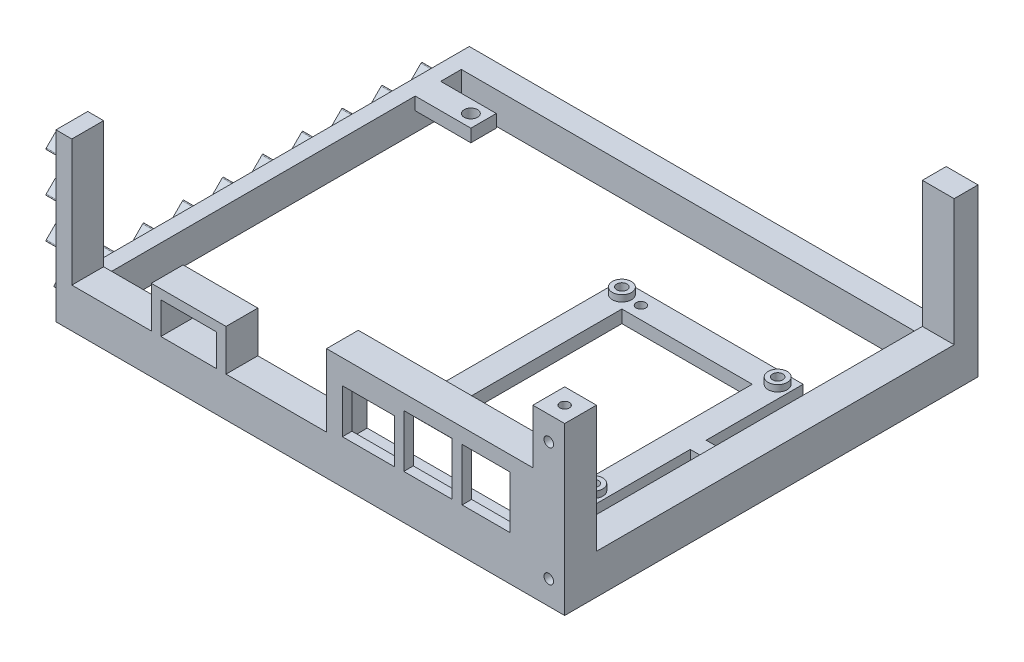
from build123d import *

# Parameters (mm, degrees)
SKETCH1_W           = 160
SKETCH1_H           = 130
BOSS_EXTRUDE1_DEPTH = 10
BOSS_EXTRUDE2_DEPTH = 42.3
CUT_EXTRUDE3_DEPTH  = 5.25
SKETCH9_R           = 2.1
CUT_EXTRUDE4_DEPTH  = 116.06211366
SKETCH11_W          = 112.5
SKETCH11_H          = 39.8
CUT_EXTRUDE5_DEPTH  = 172.640001165
SKETCH14_R          = 1.5
SKETCH14_W          = 41
SKETCH14_H          = 50
SKETCH14_R_2        = 1.625
BOSS_EXTRUDE7_DEPTH = 10
SKETCH14_3_R        = 3
SKETCH14_3_R_2      = 1.625
BOSS_EXTRUDE8_DEPTH = 12
SKETCH15_R          = 1.5
CUT_EXTRUDE7_DEPTH  = 4
CUT_EXTRUDE8_START  = -4
SKETCH16_R          = 1.5
CUT_EXTRUDE8_DEPTH  = 4
SKETCH17_W          = 17.5
SKETCH17_H          = 8
CUT_EXTRUDE9_DEPTH  = 6
SKETCH18_W          = 62.5
SKETCH18_H          = 80.5
CUT_EXTRUDE10_DEPTH = 6
SKETCH19_R          = 1.5
CUT_EXTRUDE11_DEPTH = 4
SKETCH21_W          = 16.4
SKETCH21_H          = 13.9
SKETCH21_W_2        = 15.2
SKETCH21_H_2        = 16.58376534
SKETCH21_W_3        = 15
SKETCH21_H_3        = 16.5018301
SKETCH21_W_4        = 17.5
SKETCH21_H_4        = 10
CUT_EXTRUDE14_DEPTH = 10
SKETCH22_W          = 57
SKETCH22_H          = 22.25
CUT_EXTRUDE16_DEPTH = 7
BOSS_EXTRUDE9_DEPTH = 5


with BuildPart() as part:
    # Sketch1 → Boss-Extrude1 (new body)
    with BuildSketch(Plane(origin=(0, 0, 0), x_dir=(1, 0, 0), z_dir=(0, 1, 0))):
        with Locations((5, 0)):
            Rectangle(SKETCH1_W, SKETCH1_H)
    extrude(amount=BOSS_EXTRUDE1_DEPTH)

    # Sketch3 → Boss-Extrude2 (add)
    with BuildSketch(Plane(origin=(0, 10, 0), x_dir=(1, 0, 0), z_dir=(0, 1, 0))):
        Polygon((75, 65), (75, -55), (-75, -55), (-75, -65), (85, -65), (85, 65), align=None)
    extrude(amount=BOSS_EXTRUDE2_DEPTH)

    # Sketch8 → Cut-Extrude3 (cut)
    with BuildSketch(Plane(origin=(0, 0, -65), x_dir=(-1, 0, 0), z_dir=(0, 0, -1))):
        Polygon((-83.425, 31.15), (-80, 34.575), (-76.575, 31.15), (-80, 27.725), align=None)
        Polygon((-80, 40.225), (-83.425, 43.65), (-80, 47.075), (-76.575, 43.65), align=None)
        Polygon((-80, 15.225), (-83.425, 18.65), (-80, 22.075), (-76.575, 18.65), align=None)
        Polygon((0, 8.425), (-3.425, 5), (0, 1.575), (3.425, 5), align=None)
        Polygon((15.925, 5), (12.5, 8.425), (9.075, 5), (12.5, 1.575), align=None)
        Polygon((28.425, 5), (25, 8.425), (21.575, 5), (25, 1.575), align=None)
        Polygon((40.925, 5), (37.5, 8.425), (34.075, 5), (37.5, 1.575), align=None)
        Polygon((53.425, 5), (50, 8.425), (46.575, 5), (50, 1.575), align=None)
        Polygon((65.925, 5), (62.5, 8.425), (59.075, 5), (62.5, 1.575), align=None)
        Polygon((-9.075, 5), (-12.5, 8.425), (-15.925, 5), (-12.5, 1.575), align=None)
        Polygon((-21.575, 5), (-25, 8.425), (-28.425, 5), (-25, 1.575), align=None)
        Polygon((-34.075, 5), (-37.5, 8.425), (-40.925, 5), (-37.5, 1.575), align=None)
        Polygon((-46.575, 5), (-50, 8.425), (-53.425, 5), (-50, 1.575), align=None)
        Polygon((-59.075, 5), (-62.5, 8.425), (-65.925, 5), (-62.5, 1.575), align=None)
        Polygon((-71.575, 5), (-75, 8.425), (-78.425, 5), (-75, 1.575), align=None)
    extrude(amount=-CUT_EXTRUDE3_DEPTH, mode=Mode.SUBTRACT)

    # Sketch9 → Cut-Extrude4 (cut, through all)
    with BuildSketch(Plane(origin=(0, 10, 0), x_dir=(1, 0, 0), z_dir=(0, 1, 0))):
        with Locations((-56.5, 47)):
            Circle(SKETCH9_R)
        Polygon((-70, -55), (75, -55), (75, 57.5), (-70, 57.5), (-70, 51), (-52.5, 51), (-52.5, 43), (-70, 43), align=None)
    extrude(amount=-CUT_EXTRUDE4_DEPTH, mode=Mode.SUBTRACT)

    # Sketch11 → Cut-Extrude5 (cut, through all)
    with BuildSketch(Plane.ZY.offset(-75)):
        with Locations((-1.25, 32.4)):
            Rectangle(SKETCH11_W, SKETCH11_H)
    extrude(amount=-CUT_EXTRUDE5_DEPTH, mode=Mode.SUBTRACT)

    # Sketch14 → Boss-Extrude7 (add)
    with BuildSketch(Plane(origin=(0, 0, 0), x_dir=(1, 0, 0), z_dir=(0, 1, 0))):
        Polygon((69.5, -40.5), (69.5, -9.999989951), (75, -9.999989951), (75.01417657, -5.000010049), (69.5, -5.000010049), (69.5, 25.5), (12.5, 25.5), (12.5, -40.5), align=None)
        with Locations((59.5, -36.5)):
            Circle(SKETCH14_R, mode=Mode.SUBTRACT)
        with Locations((41, -7.5)):
            Rectangle(SKETCH14_W, SKETCH14_H, mode=Mode.SUBTRACT)
        with Locations((22.5, 21.5)):
            Circle(SKETCH14_R, mode=Mode.SUBTRACT)
        with Locations((16.5, -36.5)):
            Circle(SKETCH14_R_2, mode=Mode.SUBTRACT)
        with Locations((65.5, -36.5)):
            Circle(SKETCH14_R_2, mode=Mode.SUBTRACT)
        with Locations((16.5, 21.5)):
            Circle(SKETCH14_R_2, mode=Mode.SUBTRACT)
        with Locations((65.5, 21.5)):
            Circle(SKETCH14_R_2, mode=Mode.SUBTRACT)
    extrude(amount=BOSS_EXTRUDE7_DEPTH)

    # Sketch14_3 → Boss-Extrude8 (add)
    # profile 1 of 4: a face of its own
    with BuildSketch(Plane(origin=(0, 0, 0), x_dir=(1, 0, 0), z_dir=(0, 1, 0))):
        with Locations((16.5, -36.5)):
            Circle(SKETCH14_3_R)
        with Locations((16.5, -36.5)):
            Circle(SKETCH14_3_R_2, mode=Mode.SUBTRACT)
    # profile 2 of 4: a face of its own
    with BuildSketch(Plane(origin=(0, 0, 0), x_dir=(1, 0, 0), z_dir=(0, 1, 0))):
        with Locations((65.5, -36.5)):
            Circle(SKETCH14_3_R)
        with Locations((65.5, -36.5)):
            Circle(SKETCH14_3_R_2, mode=Mode.SUBTRACT)
    # profile 3 of 4: a face of its own
    with BuildSketch(Plane(origin=(0, 0, 0), x_dir=(1, 0, 0), z_dir=(0, 1, 0))):
        with Locations((16.5, 21.5)):
            Circle(SKETCH14_3_R)
        with Locations((16.5, 21.5)):
            Circle(SKETCH14_3_R_2, mode=Mode.SUBTRACT)
    # profile 4 of 4: a face of its own
    with BuildSketch(Plane(origin=(0, 0, 0), x_dir=(1, 0, 0), z_dir=(0, 1, 0))):
        with Locations((65.5, 21.5)):
            Circle(SKETCH14_3_R)
        with Locations((65.5, 21.5)):
            Circle(SKETCH14_3_R_2, mode=Mode.SUBTRACT)
    extrude(amount=BOSS_EXTRUDE8_DEPTH)

    # Sketch15 → Cut-Extrude7 (cut)
    with BuildSketch(Plane(origin=(0, 52.3, 0), x_dir=(1, 0, 0), z_dir=(0, 1, 0))):
        with Locations((80, -60)):
            Circle(SKETCH15_R)
    extrude(amount=-CUT_EXTRUDE7_DEPTH, mode=Mode.SUBTRACT)

    # Sketch16 → Cut-Extrude8 (cut)
    with BuildSketch(Plane.XZ.offset(CUT_EXTRUDE8_START)):
        with Locations((80, 60)):
            Circle(SKETCH16_R)
    extrude(amount=CUT_EXTRUDE8_DEPTH, mode=Mode.SUBTRACT)

    # Sketch17 → Cut-Extrude9 (cut)
    with BuildSketch(Plane.XZ):
        with Locations((-61.25, -47)):
            Rectangle(SKETCH17_W, SKETCH17_H)
    extrude(amount=-CUT_EXTRUDE9_DEPTH, mode=Mode.SUBTRACT)

    # Sketch18 → Cut-Extrude10 (cut)
    with BuildSketch(Plane.XZ):
        with Locations((43.75, 14.75)):
            Rectangle(SKETCH18_W, SKETCH18_H)
    extrude(amount=-CUT_EXTRUDE10_DEPTH, mode=Mode.SUBTRACT)

    # Sketch19 → Cut-Extrude11 (cut)
    with BuildSketch(Plane.XY.offset(65)):
        with Locations((80, 7.5)):
            Circle(SKETCH19_R)
        with Locations((80, 44.8)):
            Circle(SKETCH19_R)
    extrude(amount=-CUT_EXTRUDE11_DEPTH, mode=Mode.SUBTRACT)

    # Sketch21 → Cut-Extrude14 (cut)
    with BuildSketch(Plane.XY.offset(65)):
        Polygon((-70, 52.3), (-70, 12.5), (-45, 12.5), (-45, 25.5), (-21.5, 25.5), (-21.5, 12.5), (10.1, 12.5), (10.1, 35.25), (75, 35.25), (75, 52.3), align=None)
        with Locations((23.3, 20.7)):
            Rectangle(SKETCH21_W, SKETCH21_H)
        with Locations((42, 22.25)):
            Rectangle(SKETCH21_W_2, SKETCH21_H_2)
        with Locations((60.25, 22.25)):
            Rectangle(SKETCH21_W_3, SKETCH21_H_3)
        with Locations((-33.25, 17.5)):
            Rectangle(SKETCH21_W_4, SKETCH21_H_4)
    extrude(amount=-CUT_EXTRUDE14_DEPTH, mode=Mode.SUBTRACT)

    # Sketch22 → Cut-Extrude16 (cut)
    with BuildSketch(Plane(origin=(0, 0, 55), x_dir=(-1, 0, 0), z_dir=(0, 0, -1))):
        with Locations((-41.4, 21.125)):
            Rectangle(SKETCH22_W, SKETCH22_H)
    extrude(amount=-CUT_EXTRUDE16_DEPTH, mode=Mode.SUBTRACT)

    # Sketch10 → Boss-Extrude9 (add)
    with BuildSketch(Plane.ZY.offset(75)):
        with BuildLine():
            Line((10.537867966, 5.212132034), (7.712132034, 8.037867966))
            ThreePointArc((7.712132034, 8.037867966), (7.5, 8.125735931), (7.287867966, 8.037867966))
            Line((7.287867966, 8.037867966), (4.462132034, 5.212132034))
            ThreePointArc((4.462132034, 5.212132034), (4.374264069, 5), (4.462132034, 4.787867966))
            Line((4.462132034, 4.787867966), (7.287867966, 1.962132034))
            ThreePointArc((7.287867966, 1.962132034), (7.5, 1.874264069), (7.712132034, 1.962132034))
            Line((7.712132034, 1.962132034), (10.537867966, 4.787867966))
            ThreePointArc((10.537867966, 4.787867966), (10.625735931, 5), (10.537867966, 5.212132034))
        make_face()
        with BuildLine():
            Line((56.962132034, 31.362132034), (59.787867966, 34.187867966))
            ThreePointArc((59.787867966, 34.187867966), (60, 34.275735931), (60.212132034, 34.187867966))
            Line((60.212132034, 34.187867966), (63.037867966, 31.362132034))
            ThreePointArc((63.037867966, 31.362132034), (63.125735931, 31.15), (63.037867966, 30.937867966))
            Line((63.037867966, 30.937867966), (60.212132034, 28.112132034))
            ThreePointArc((60.212132034, 28.112132034), (60, 28.024264069), (59.787867966, 28.112132034))
            Line((59.787867966, 28.112132034), (56.962132034, 30.937867966))
            ThreePointArc((56.962132034, 30.937867966), (56.874264069, 31.15), (56.962132034, 31.362132034))
        make_face()
        with BuildLine():
            Line((-5.212132034, 8.037867966), (-8.037867966, 5.212132034))
            ThreePointArc((-8.037867966, 5.212132034), (-8.125735931, 5), (-8.037867966, 4.787867966))
            Line((-8.037867966, 4.787867966), (-5.212132034, 1.962132034))
            ThreePointArc((-5.212132034, 1.962132034), (-5, 1.874264069), (-4.787867966, 1.962132034))
            Line((-4.787867966, 1.962132034), (-1.962132034, 4.787867966))
            ThreePointArc((-1.962132034, 4.787867966), (-1.874264069, 5), (-1.962132034, 5.212132034))
            Line((-1.962132034, 5.212132034), (-4.787867966, 8.037867966))
            ThreePointArc((-4.787867966, 8.037867966), (-5, 8.125735931), (-5.212132034, 8.037867966))
        make_face()
        with BuildLine():
            Line((59.787867966, 40.612132034), (56.962132034, 43.437867966))
            ThreePointArc((56.962132034, 43.437867966), (56.874264069, 43.65), (56.962132034, 43.862132034))
            Line((56.962132034, 43.862132034), (59.787867966, 46.687867966))
            ThreePointArc((59.787867966, 46.687867966), (60, 46.775735931), (60.212132034, 46.687867966))
            Line((60.212132034, 46.687867966), (63.037867966, 43.862132034))
            ThreePointArc((63.037867966, 43.862132034), (63.125735931, 43.65), (63.037867966, 43.437867966))
            Line((63.037867966, 43.437867966), (60.212132034, 40.612132034))
            ThreePointArc((60.212132034, 40.612132034), (60, 40.524264069), (59.787867966, 40.612132034))
        make_face()
        with BuildLine():
            Line((59.787867966, 15.612132034), (56.962132034, 18.437867966))
            ThreePointArc((56.962132034, 18.437867966), (56.874264069, 18.65), (56.962132034, 18.862132034))
            Line((56.962132034, 18.862132034), (59.787867966, 21.687867966))
            ThreePointArc((59.787867966, 21.687867966), (60, 21.775735931), (60.212132034, 21.687867966))
            Line((60.212132034, 21.687867966), (63.037867966, 18.862132034))
            ThreePointArc((63.037867966, 18.862132034), (63.125735931, 18.65), (63.037867966, 18.437867966))
            Line((63.037867966, 18.437867966), (60.212132034, 15.612132034))
            ThreePointArc((60.212132034, 15.612132034), (60, 15.524264069), (59.787867966, 15.612132034))
        make_face()
        with BuildLine():
            Line((23.037867966, 5.212132034), (20.212132034, 8.037867966))
            ThreePointArc((20.212132034, 8.037867966), (20, 8.125735931), (19.787867966, 8.037867966))
            Line((19.787867966, 8.037867966), (16.962132034, 5.212132034))
            ThreePointArc((16.962132034, 5.212132034), (16.874264069, 5), (16.962132034, 4.787867966))
            Line((16.962132034, 4.787867966), (19.787867966, 1.962132034))
            ThreePointArc((19.787867966, 1.962132034), (20, 1.874264069), (20.212132034, 1.962132034))
            Line((20.212132034, 1.962132034), (23.037867966, 4.787867966))
            ThreePointArc((23.037867966, 4.787867966), (23.125735931, 5), (23.037867966, 5.212132034))
        make_face()
        with BuildLine():
            Line((35.537867966, 5.212132034), (32.712132034, 8.037867966))
            ThreePointArc((32.712132034, 8.037867966), (32.5, 8.125735931), (32.287867966, 8.037867966))
            Line((32.287867966, 8.037867966), (29.462132034, 5.212132034))
            ThreePointArc((29.462132034, 5.212132034), (29.374264069, 5), (29.462132034, 4.787867966))
            Line((29.462132034, 4.787867966), (32.287867966, 1.962132034))
            ThreePointArc((32.287867966, 1.962132034), (32.5, 1.874264069), (32.712132034, 1.962132034))
            Line((32.712132034, 1.962132034), (35.537867966, 4.787867966))
            ThreePointArc((35.537867966, 4.787867966), (35.625735931, 5), (35.537867966, 5.212132034))
        make_face()
        with BuildLine():
            Line((48.037867966, 5.212132034), (45.212132034, 8.037867966))
            ThreePointArc((45.212132034, 8.037867966), (45, 8.125735931), (44.787867966, 8.037867966))
            Line((44.787867966, 8.037867966), (41.962132034, 5.212132034))
            ThreePointArc((41.962132034, 5.212132034), (41.874264069, 5), (41.962132034, 4.787867966))
            Line((41.962132034, 4.787867966), (44.787867966, 1.962132034))
            ThreePointArc((44.787867966, 1.962132034), (45, 1.874264069), (45.212132034, 1.962132034))
            Line((45.212132034, 1.962132034), (48.037867966, 4.787867966))
            ThreePointArc((48.037867966, 4.787867966), (48.125735931, 5), (48.037867966, 5.212132034))
        make_face()
        with BuildLine():
            Line((60.537867966, 5.212132034), (57.712132034, 8.037867966))
            ThreePointArc((57.712132034, 8.037867966), (57.5, 8.125735931), (57.287867966, 8.037867966))
            Line((57.287867966, 8.037867966), (54.462132034, 5.212132034))
            ThreePointArc((54.462132034, 5.212132034), (54.374264069, 5), (54.462132034, 4.787867966))
            Line((54.462132034, 4.787867966), (57.287867966, 1.962132034))
            ThreePointArc((57.287867966, 1.962132034), (57.5, 1.874264069), (57.712132034, 1.962132034))
            Line((57.712132034, 1.962132034), (60.537867966, 4.787867966))
            ThreePointArc((60.537867966, 4.787867966), (60.625735931, 5), (60.537867966, 5.212132034))
        make_face()
        with BuildLine():
            Line((-14.462132034, 5.212132034), (-17.287867966, 8.037867966))
            ThreePointArc((-17.287867966, 8.037867966), (-17.5, 8.125735931), (-17.712132034, 8.037867966))
            Line((-17.712132034, 8.037867966), (-20.537867966, 5.212132034))
            ThreePointArc((-20.537867966, 5.212132034), (-20.625735931, 5), (-20.537867966, 4.787867966))
            Line((-20.537867966, 4.787867966), (-17.712132034, 1.962132034))
            ThreePointArc((-17.712132034, 1.962132034), (-17.5, 1.874264069), (-17.287867966, 1.962132034))
            Line((-17.287867966, 1.962132034), (-14.462132034, 4.787867966))
            ThreePointArc((-14.462132034, 4.787867966), (-14.374264069, 5), (-14.462132034, 5.212132034))
        make_face()
        with BuildLine():
            Line((-26.962132034, 5.212132034), (-29.787867966, 8.037867966))
            ThreePointArc((-29.787867966, 8.037867966), (-30, 8.125735931), (-30.212132034, 8.037867966))
            Line((-30.212132034, 8.037867966), (-33.037867966, 5.212132034))
            ThreePointArc((-33.037867966, 5.212132034), (-33.125735931, 5), (-33.037867966, 4.787867966))
            Line((-33.037867966, 4.787867966), (-30.212132034, 1.962132034))
            ThreePointArc((-30.212132034, 1.962132034), (-30, 1.874264069), (-29.787867966, 1.962132034))
            Line((-29.787867966, 1.962132034), (-26.962132034, 4.787867966))
            ThreePointArc((-26.962132034, 4.787867966), (-26.874264069, 5), (-26.962132034, 5.212132034))
        make_face()
        with BuildLine():
            Line((-39.462132034, 5.212132034), (-42.287867966, 8.037867966))
            ThreePointArc((-42.287867966, 8.037867966), (-42.5, 8.125735931), (-42.712132034, 8.037867966))
            Line((-42.712132034, 8.037867966), (-45.537867966, 5.212132034))
            ThreePointArc((-45.537867966, 5.212132034), (-45.625735931, 5), (-45.537867966, 4.787867966))
            Line((-45.537867966, 4.787867966), (-42.712132034, 1.962132034))
            ThreePointArc((-42.712132034, 1.962132034), (-42.5, 1.874264069), (-42.287867966, 1.962132034))
            Line((-42.287867966, 1.962132034), (-39.462132034, 4.787867966))
            ThreePointArc((-39.462132034, 4.787867966), (-39.374264069, 5), (-39.462132034, 5.212132034))
        make_face()
        with BuildLine():
            Line((-51.962132034, 5.212132034), (-54.787867966, 8.037867966))
            ThreePointArc((-54.787867966, 8.037867966), (-55, 8.125735931), (-55.212132034, 8.037867966))
            Line((-55.212132034, 8.037867966), (-58.037867966, 5.212132034))
            ThreePointArc((-58.037867966, 5.212132034), (-58.125735931, 5), (-58.037867966, 4.787867966))
            Line((-58.037867966, 4.787867966), (-55.212132034, 1.962132034))
            ThreePointArc((-55.212132034, 1.962132034), (-55, 1.874264069), (-54.787867966, 1.962132034))
            Line((-54.787867966, 1.962132034), (-51.962132034, 4.787867966))
            ThreePointArc((-51.962132034, 4.787867966), (-51.874264069, 5), (-51.962132034, 5.212132034))
        make_face()
    extrude(amount=BOSS_EXTRUDE9_DEPTH)


solid = part.part
